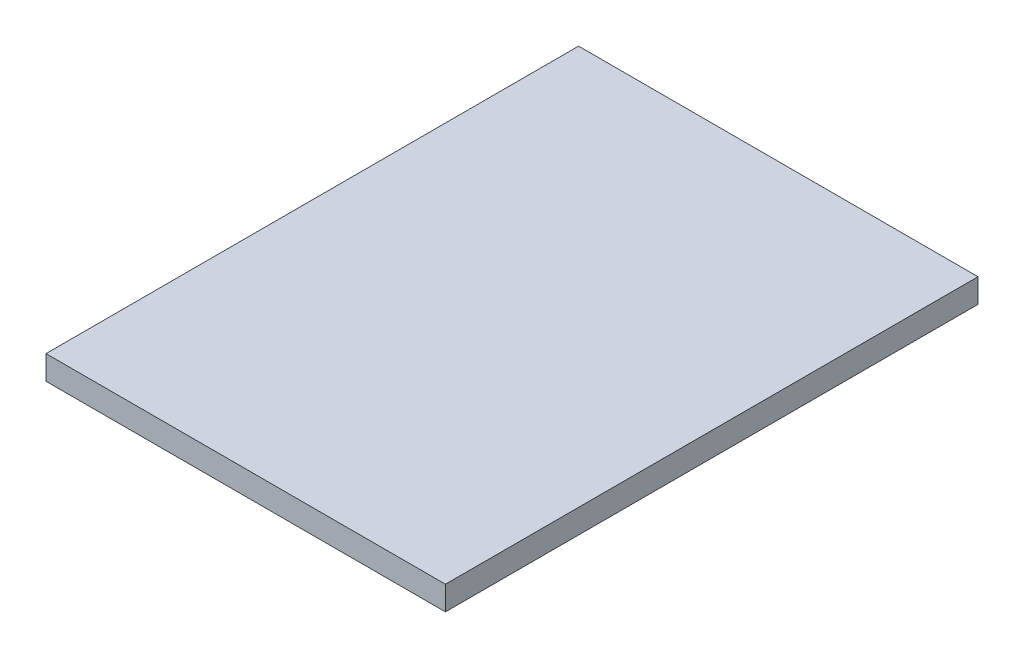
from build123d import *

# Parameters (mm, degrees)
SKETCH1_W           = 300
SKETCH1_H           = 400
BOSS_EXTRUDE1_DEPTH = 18


with BuildPart() as part:
    # Sketch1 → Boss-Extrude1 (new body)
    with BuildSketch(Plane(origin=(0, 0, 0), x_dir=(1, 0, 0), z_dir=(0, 1, 0))):
        with Locations((150, 200)):
            Rectangle(SKETCH1_W, SKETCH1_H)
    extrude(amount=BOSS_EXTRUDE1_DEPTH)


solid = part.part
